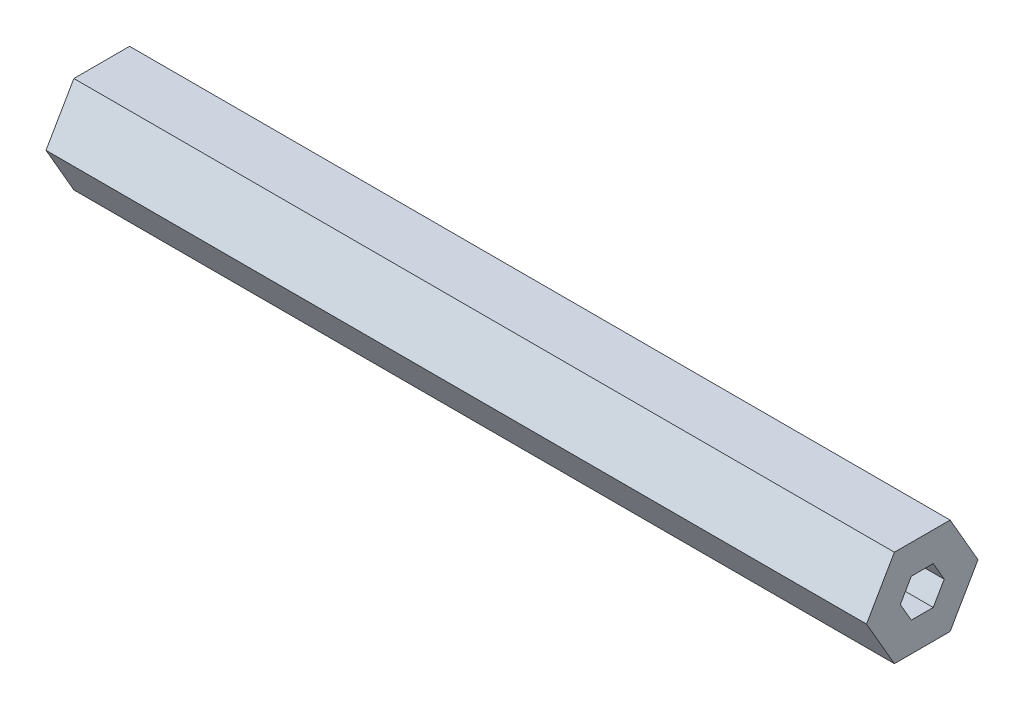
from build123d import *

# Parameters (mm, degrees)
BOSS_EXTRUDE1_DEPTH = 107.95


with BuildPart() as part:
    # Sketch1 → Boss-Extrude1 (new body)
    with BuildSketch(Plane(origin=(0, 0, 0), x_dir=(0, 0, -1), z_dir=(1, 0, 0))):
        Polygon((7.332348419, 0), (3.666174209, 6.35), (-3.666174209, 6.35), (-7.332348419, 0), (-3.666174209, -6.35), (3.666174209, -6.35), align=None)
        Polygon((2.886751346, 0), (1.443375673, 2.5), (-1.443375673, 2.5), (-2.886751346, 0), (-1.443375673, -2.5), (1.443375673, -2.5), align=None, mode=Mode.SUBTRACT)
    extrude(amount=BOSS_EXTRUDE1_DEPTH)


solid = part.part
